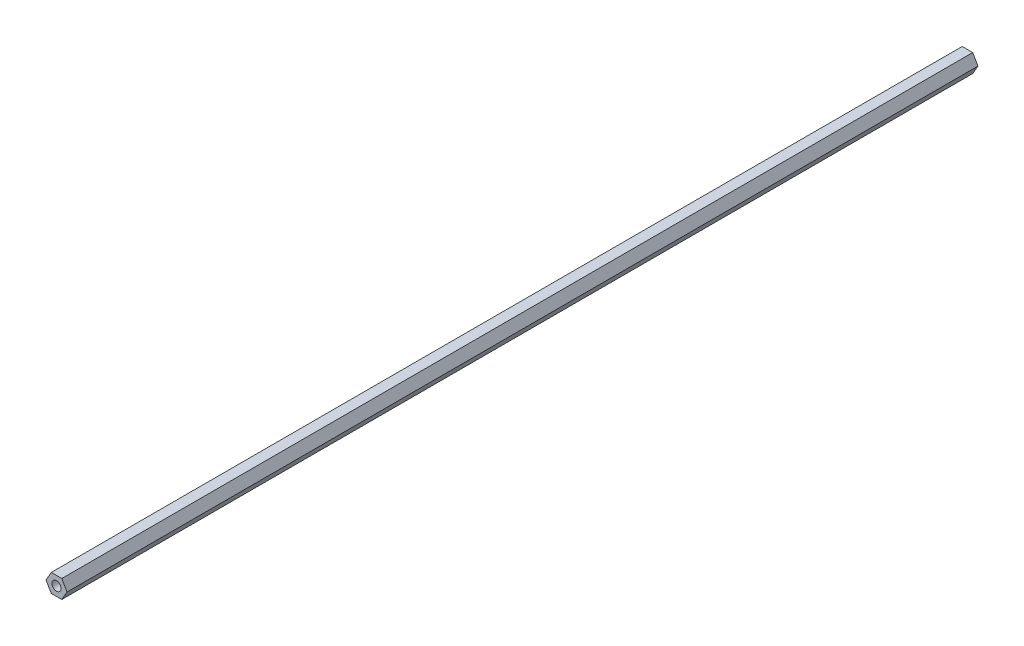
from build123d import *

# Parameters (mm, degrees)
SKETCH1_R           = 3.175
BOSS_EXTRUDE1_DEPTH = 635


with BuildPart() as part:
    # Sketch1 → Boss-Extrude1 (new body)
    with BuildSketch(Plane.XY):
        Polygon((-3.666174209, 6.35), (-7.332348419, 0), (-3.666174209, -6.35), (3.666174209, -6.35), (7.332348419, 0), (3.666174209, 6.35), align=None)
        Circle(SKETCH1_R, mode=Mode.SUBTRACT)
    extrude(amount=BOSS_EXTRUDE1_DEPTH)


solid = part.part
